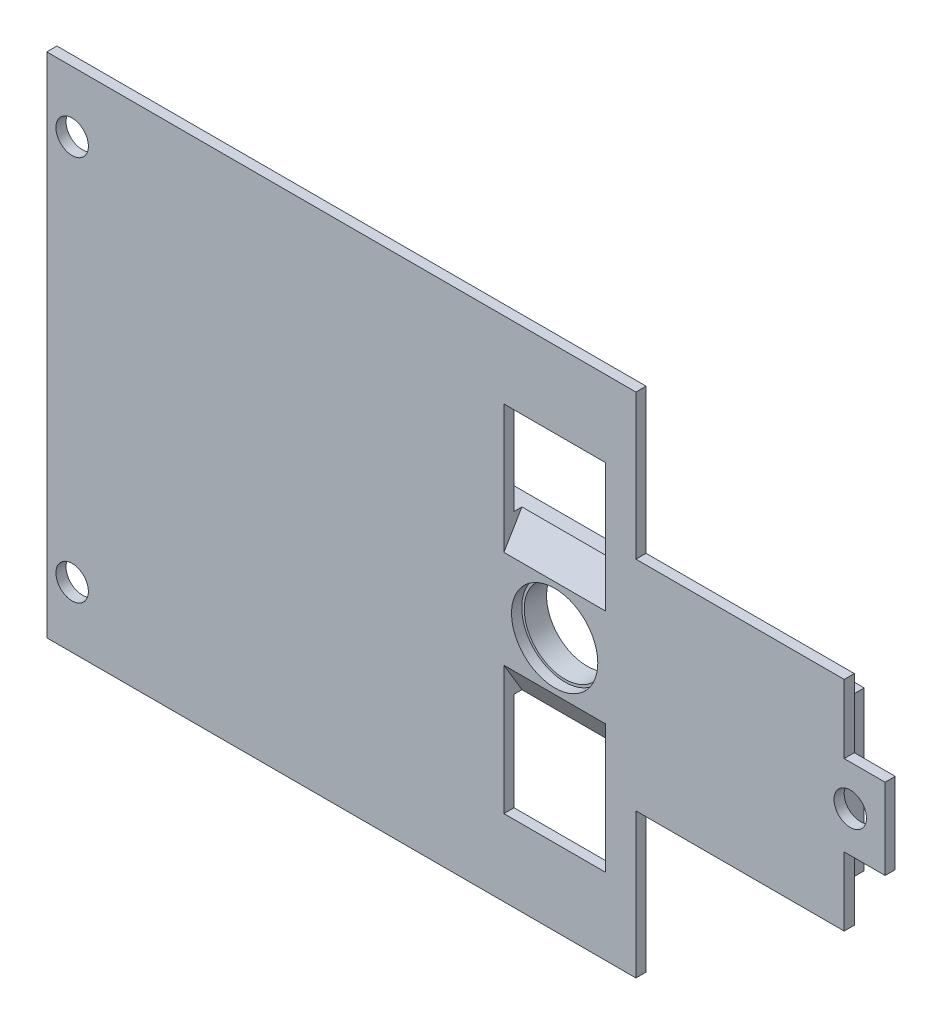
from build123d import *

# Parameters (mm, degrees)
SKETCH4_R           = 1.6
BOSS_EXTRUDE2_DEPTH = 1
BOSS_EXTRUDE3_DEPTH = 2.2
SKETCH6_R           = 4
SKETCH6_W           = 10.008556046
SKETCH6_H           = 9.470821567
CUT_EXTRUDE1_DEPTH  = 4.2
CUT_EXTRUDE2_DEPTH  = 10.008556
SKETCH8_W           = 2.5
SKETCH8_H           = 24.6
BOSS_EXTRUDE4_DEPTH = 10
CUT_EXTRUDE3_REACH  = 84.598
SKETCH10_R          = 4.25
CUT_EXTRUDE4_DEPTH  = 1


with BuildPart() as part:
    # Sketch4 → Boss-Extrude2 (new body)
    with BuildSketch(Plane.XY):
        Polygon((-50.042780229, 25), (8.006844837, 25), (8.006844837, 10.737807635), (28.52438473, 10.737807635), (28.52438473, 3.982032304), (32.555371359, 3.982032304), (32.555371359, -3.982032304), (28.52438473, -3.982032304), (28.52438473, -10.737807635), (8.006844837, -10.737807635), (8.006844837, -25), (-50.042780229, -25), align=None)
        with Locations((-47.542780229, 19)):
            Circle(SKETCH4_R, mode=Mode.SUBTRACT)
        with Locations((-47.542780229, -19)):
            Circle(SKETCH4_R, mode=Mode.SUBTRACT)
        with Locations((29.123529126, 0)):
            Circle(SKETCH4_R, mode=Mode.SUBTRACT)
    extrude(amount=BOSS_EXTRUDE2_DEPTH)

    # Sketch5 → Boss-Extrude3 (add)
    with BuildSketch(Plane(origin=(0, 0, 0), x_dir=(-1, 0, 0), z_dir=(0, 0, -1))):
        Polygon((10.130686795, 7.8), (-27.3, 7.8), (-27.3, -7.8), (10.130686795, -7.8), (10.416393564, -7.8), (10.416393564, -8), (10.416393564, -25), (27.916393564, -25), (27.916393564, -22.8), (42.575341492, -22.8), (42.575341492, -12.3), (50.042780229, -12.3), (50.042780229, 12.3), (42.575341492, 12.3), (42.575341492, 22.8), (10.416393564, 22.8), (10.416393564, 8), (10.416393564, 7.8), align=None)
    extrude(amount=BOSS_EXTRUDE3_DEPTH)

    # Sketch6 → Cut-Extrude1 (cut, through all)
    with BuildSketch(Plane.XY.offset(1)):
        Circle(SKETCH6_R)
        with Locations((0, -12.74225562)):
            Rectangle(SKETCH6_W, SKETCH6_H)
        with Locations((0, 12.74225562)):
            Rectangle(SKETCH6_W, SKETCH6_H)
    extrude(amount=-CUT_EXTRUDE1_DEPTH, mode=Mode.SUBTRACT)

    # Sketch7 → Cut-Extrude2 (cut)
    with BuildSketch(Plane(origin=(-5.004278023, 0, 0), x_dir=(0, 0, -1), z_dir=(1, 0, 0))):
        Polygon((0.904413332, -8.006844837), (-1, -4.814198104), (-1, -8.006844837), (0, -8.006844837), align=None)
    cut_extrude2 = extrude(amount=CUT_EXTRUDE2_DEPTH, mode=Mode.SUBTRACT)

    # Mirror1: Cut-Extrude2 across plane
    add(cut_extrude2.mirror(Plane.ZX), mode=Mode.SUBTRACT)

    # Sketch8 → Boss-Extrude4 (add)
    with BuildSketch(Plane(origin=(0, 0, -2.2), x_dir=(-1, 0, 0), z_dir=(0, 0, -1))):
        with Locations((48.792780229, 0)):
            Rectangle(SKETCH8_W, SKETCH8_H)
    extrude(amount=BOSS_EXTRUDE4_DEPTH)

    # Sketch9 → Cut-Extrude3 (cut, up to next)
    with BuildSketch(Plane.ZY.offset(50.042780229), mode=Mode.PRIVATE) as cut_extrude3_sk1:
        with BuildLine():
            Line((-9.2, 9.061272662), (-12.2, 9.061272662))
            Line((-12.2, 9.061272662), (-12.2, 5.087082771))
            Line((-12.2, 5.087082771), (-9.2, 5.087082771))
            ThreePointArc((-9.2, 5.087082771), (-7.212905055, 7.074177716), (-9.2, 9.061272662))
        make_face()
    cut_extrude3_tool1 = extrude(cut_extrude3_sk1.sketch, amount=-CUT_EXTRUDE3_REACH, mode=Mode.PRIVATE) & part.part
    add(cut_extrude3_tool1.solids().sort_by_distance((-50.04278, 7.074178, -9.898105))[0], mode=Mode.SUBTRACT)

    # Sketch10 → Cut-Extrude4 (cut)
    with BuildSketch(Plane.XY.offset(1)):
        Circle(SKETCH10_R)
    extrude(amount=-CUT_EXTRUDE4_DEPTH, mode=Mode.SUBTRACT)


solid = part.part
